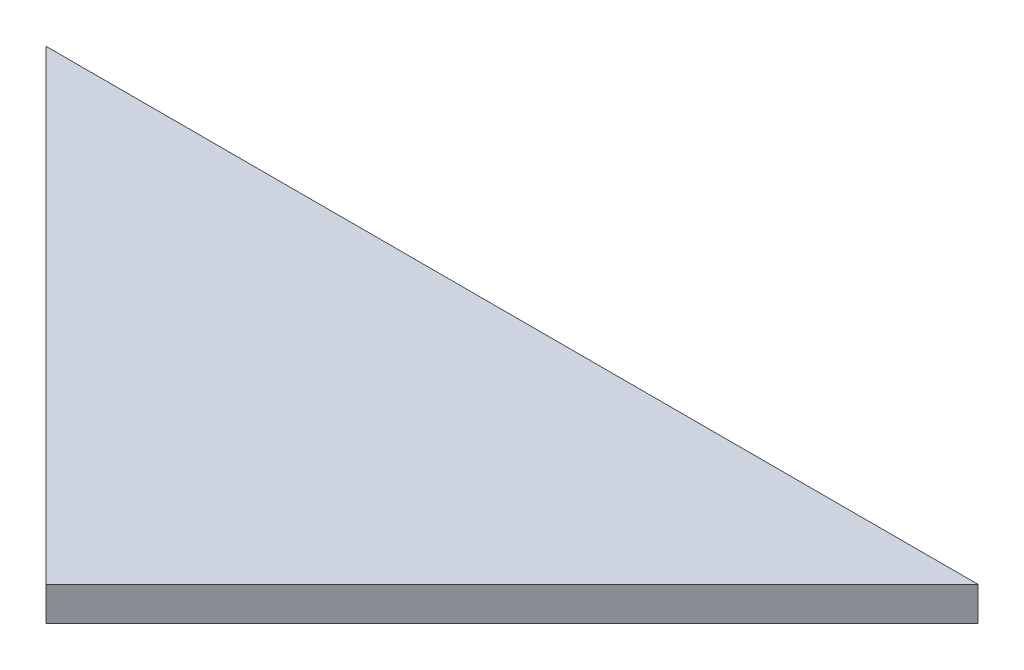
from build123d import *

# Parameters (mm, degrees)
BOSS_EXTRUDE1_DEPTH = 1.5


with BuildPart() as part:
    # Sketch1 → Boss-Extrude1 (new body, symmetric)
    with BuildSketch(Plane(origin=(0, -113.704878, 0), x_dir=(-1, 0, 0), z_dir=(0, -1, 0))):
        Polygon((40.966000127, -116.244878), (-40.966000127, -116.244878), (0, -157.210878127), align=None)
    extrude(amount=BOSS_EXTRUDE1_DEPTH, both=True)


solid = part.part
